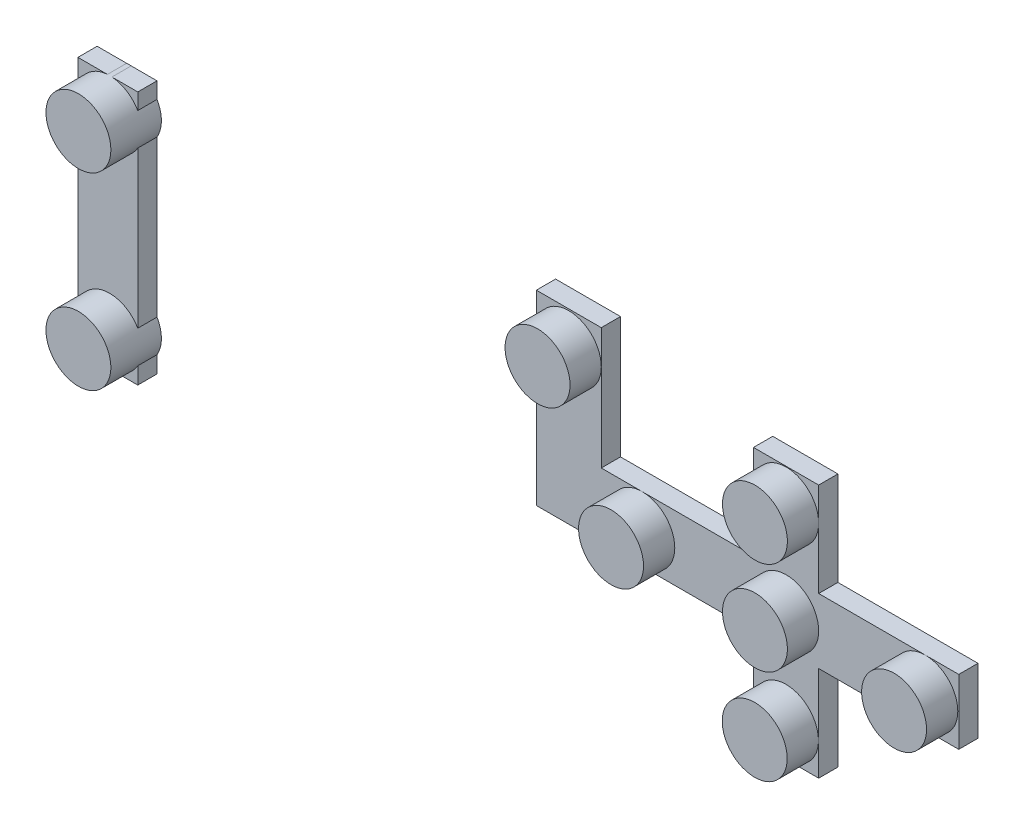
from build123d import *

# Parameters (mm, degrees)
SKETCH1_R                  = 3.429
BOSS_EXTRUDE1_DEPTH        = 3.81
BOSS_EXTRUDE1_DEPTH_BACK   = 1.524
BOSS_EXTRUDE1_2_DEPTH      = 3.81
BOSS_EXTRUDE1_2_DEPTH_BACK = 1.524
BOSS_EXTRUDE1_3_DEPTH      = 3.81
BOSS_EXTRUDE1_3_DEPTH_BACK = 1.524
BOSS_EXTRUDE1_4_DEPTH      = 3.81
BOSS_EXTRUDE1_4_DEPTH_BACK = 1.524
BOSS_EXTRUDE1_5_DEPTH      = 3.81
BOSS_EXTRUDE1_5_DEPTH_BACK = 1.524
BOSS_EXTRUDE1_6_DEPTH      = 3.81
BOSS_EXTRUDE1_6_DEPTH_BACK = 1.524
BOSS_EXTRUDE1_7_DEPTH      = 3.81
BOSS_EXTRUDE1_7_DEPTH_BACK = 1.524
BOSS_EXTRUDE1_8_DEPTH      = 3.81
BOSS_EXTRUDE1_8_DEPTH_BACK = 1.524
SKETCH2_W                  = 6.324370589
SKETCH2_H                  = 26.812883823
BOSS_EXTRUDE2_DEPTH        = 2.032


with BuildPart() as part:
    # Sketch1 → Boss-Extrude1 (new body, two sides)
    with BuildSketch(Plane.XY) as boss_extrude1_sk:
        with Locations((3027.248279136, 13530.507714547)):
            Circle(SKETCH1_R)
    extrude(amount=BOSS_EXTRUDE1_DEPTH)
    extrude(boss_extrude1_sk.sketch, amount=-BOSS_EXTRUDE1_DEPTH_BACK)



with BuildPart() as body_2:
    # Sketch1 → Boss-Extrude1 2 (new body, two sides)
    with BuildSketch(Plane.XY) as boss_extrude1_2_sk:
        with Locations((3027.248279136, 13520.653009344)):
            Circle(SKETCH1_R)
    extrude(amount=BOSS_EXTRUDE1_2_DEPTH)
    extrude(boss_extrude1_2_sk.sketch, amount=-BOSS_EXTRUDE1_2_DEPTH_BACK)


with BuildPart() as body_3:
    # Sketch1 → Boss-Extrude1 3 (new body, two sides)
    with BuildSketch(Plane.XY) as boss_extrude1_3_sk:
        with Locations((3027.222481478, 13510.622681626)):
            Circle(SKETCH1_R)
    extrude(amount=BOSS_EXTRUDE1_3_DEPTH)
    extrude(boss_extrude1_3_sk.sketch, amount=-BOSS_EXTRUDE1_3_DEPTH_BACK)


with BuildPart() as body_4:
    # Sketch1 → Boss-Extrude1 4 (new body, two sides)
    with BuildSketch(Plane.XY) as boss_extrude1_4_sk:
        with Locations((3041.941037356, 13520.653009344)):
            Circle(SKETCH1_R)
    extrude(amount=BOSS_EXTRUDE1_4_DEPTH)
    extrude(boss_extrude1_4_sk.sketch, amount=-BOSS_EXTRUDE1_4_DEPTH_BACK)


with BuildPart() as body_5:
    # Sketch1 → Boss-Extrude1 5 (new body, two sides)
    with BuildSketch(Plane.XY) as boss_extrude1_5_sk:
        with Locations((3012.050482156, 13520.653009344)):
            Circle(SKETCH1_R)
    extrude(amount=BOSS_EXTRUDE1_5_DEPTH)
    extrude(boss_extrude1_5_sk.sketch, amount=-BOSS_EXTRUDE1_5_DEPTH_BACK)


with BuildPart() as body_6:
    # Sketch1 → Boss-Extrude1 6 (new body, two sides)
    with BuildSketch(Plane.XY) as boss_extrude1_6_sk:
        with Locations((3004.288365233, 13533.330572833)):
            Circle(SKETCH1_R)
    extrude(amount=BOSS_EXTRUDE1_6_DEPTH)
    extrude(boss_extrude1_6_sk.sketch, amount=-BOSS_EXTRUDE1_6_DEPTH_BACK)


with BuildPart() as body_7:
    # Sketch1 → Boss-Extrude1 7 (new body, two sides)
    with BuildSketch(Plane.XY) as boss_extrude1_7_sk:
        with Locations((2955.799681977, 13530.583123085)):
            Circle(SKETCH1_R)
    extrude(amount=BOSS_EXTRUDE1_7_DEPTH)
    extrude(boss_extrude1_7_sk.sketch, amount=-BOSS_EXTRUDE1_7_DEPTH_BACK)


with BuildPart() as body_8:
    # Sketch1 → Boss-Extrude1 8 (new body, two sides)
    with BuildSketch(Plane.XY) as boss_extrude1_8_sk:
        with Locations((2955.799681977, 13510.673284723)):
            Circle(SKETCH1_R)
    extrude(amount=BOSS_EXTRUDE1_8_DEPTH)
    extrude(boss_extrude1_8_sk.sketch, amount=-BOSS_EXTRUDE1_8_DEPTH_BACK)


with BuildPart() as part_1:
    add(part.part)

    add(body_2.part)  # Boss-Extrude2 merges body 2

    add(body_3.part)  # Boss-Extrude2 merges body 3

    add(body_4.part)  # Boss-Extrude2 merges body 4

    add(body_5.part)  # Boss-Extrude2 merges body 5

    add(body_6.part)  # Boss-Extrude2 merges body 6

    add(body_7.part)  # Boss-Extrude2 merges body 7

    add(body_8.part)  # Boss-Extrude2 merges body 8
    # Sketch2 → Boss-Extrude2 (add)
    with BuildSketch(Plane.XY.offset(-1.524)):
        Polygon((3030.677279136, 13517.224009344), (3030.677279136, 13510.622681626), (3030.677279136, 13507.190904571), (3023.793481478, 13507.190904571), (3023.793481478, 13510.622681626), (3023.793481478, 13517.224009344), (3012.050482156, 13517.224009344), (3007.717365233, 13517.224009344), (3000.859365233, 13517.224009344), (3000.859365233, 13533.330572833), (3000.859365233, 13536.919471065), (3007.717365233, 13536.919471065), (3007.717365233, 13533.330572833), (3007.717365233, 13524.082009344), (3012.050482156, 13524.082009344), (3023.793481478, 13524.082009344), (3023.793481478, 13530.507714547), (3023.793481478, 13534.003788394), (3030.677279136, 13534.003788394), (3030.677279136, 13530.507714547), (3030.677279136, 13524.082009344), (3041.941037356, 13524.082009344), (3045.471415541, 13524.082009344), (3045.471415541, 13517.224009344), (3041.941037356, 13517.224009344), align=None)
        with Locations((2955.605463986, 13520.597346483)):
            Rectangle(SKETCH2_W, SKETCH2_H)
    extrude(amount=BOSS_EXTRUDE2_DEPTH)


solid = part_1.part
